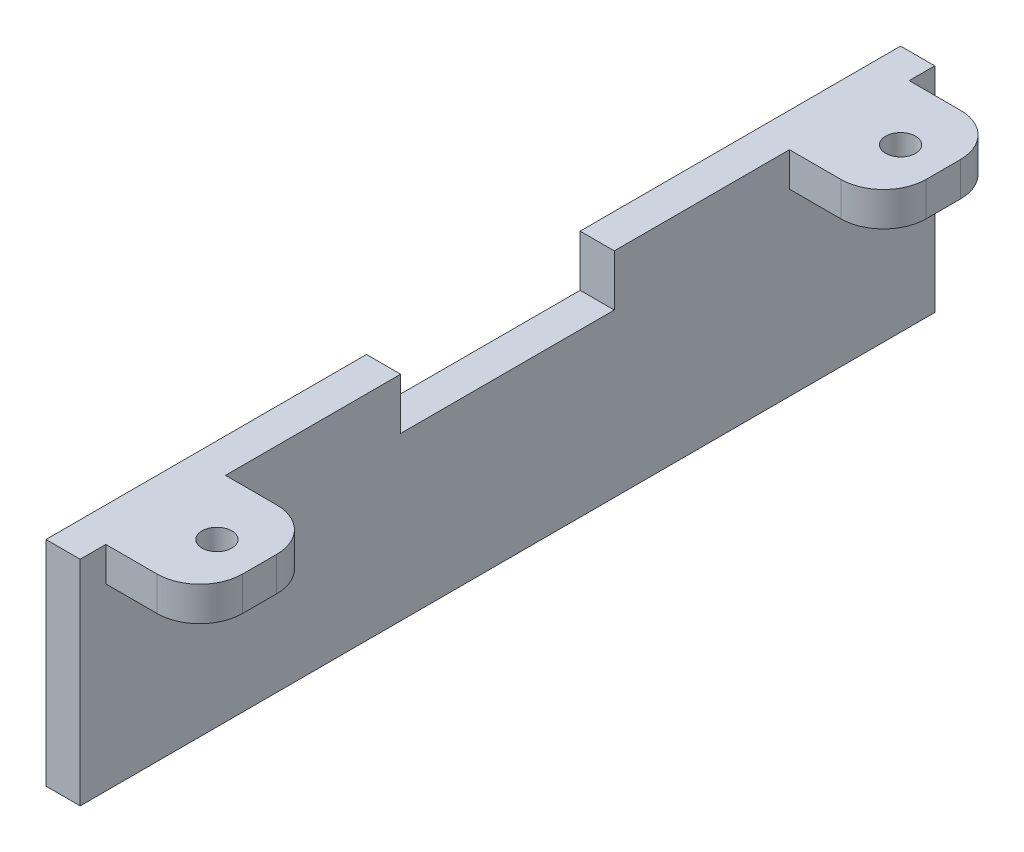
from build123d import *

# Parameters (mm, degrees)
RESSALTO_EXTRUS_O1_DEPTH = 100
ESBO_O2_R                = 1.75
ESBO_O2_W                = 11
ESBO_O2_H                = 3
ESBO_O2_H_2              = 66
CORTE_EXTRUS_O1_DEPTH    = 100
FILETE1_R                = 5
ESBO_O3_W                = 25
ESBO_O3_H                = 12
CORTE_EXTRUS_O2_DEPTH    = 100


with BuildPart() as part:
    # Esboço1 → Ressalto-extrusão1 (new body)
    with BuildSketch(Plane.XY):
        Polygon((15, 0), (0, 0), (0, -25), (4, -25), (4, -4), (15, -4), align=None)
    extrude(amount=RESSALTO_EXTRUS_O1_DEPTH)

    # Esboço2 → Corte-extrusão1 (cut)
    with BuildSketch(Plane(origin=(0, 0, 0), x_dir=(1, 0, 0), z_dir=(0, 1, 0))):
        with Locations((10, -10)):
            Circle(ESBO_O2_R)
        with Locations((10, -90)):
            Circle(ESBO_O2_R)
        with Locations((9.5, -1.5)):
            Rectangle(ESBO_O2_W, ESBO_O2_H)
        with Locations((9.5, -50)):
            Rectangle(ESBO_O2_W, ESBO_O2_H_2)
        with Locations((9.5, -98.5)):
            Rectangle(ESBO_O2_W, ESBO_O2_H)
    extrude(amount=-CORTE_EXTRUS_O1_DEPTH, mode=Mode.SUBTRACT)

    # Filete1
    filete1_edges = [part.edges().sort_by_distance(p)[0] for p in [
        (15, -2, 97),
        (15, -2, 3),
        (15, -2, 17),
        (15, -2, 83),
    ]]
    fillet(filete1_edges, radius=FILETE1_R)

    # Esboço3 → Corte-extrusão2 (cut)
    with BuildSketch(Plane.ZY):
        with Locations((50, 0)):
            Rectangle(ESBO_O3_W, ESBO_O3_H)
    extrude(amount=-CORTE_EXTRUS_O2_DEPTH, mode=Mode.SUBTRACT)


solid = part.part
